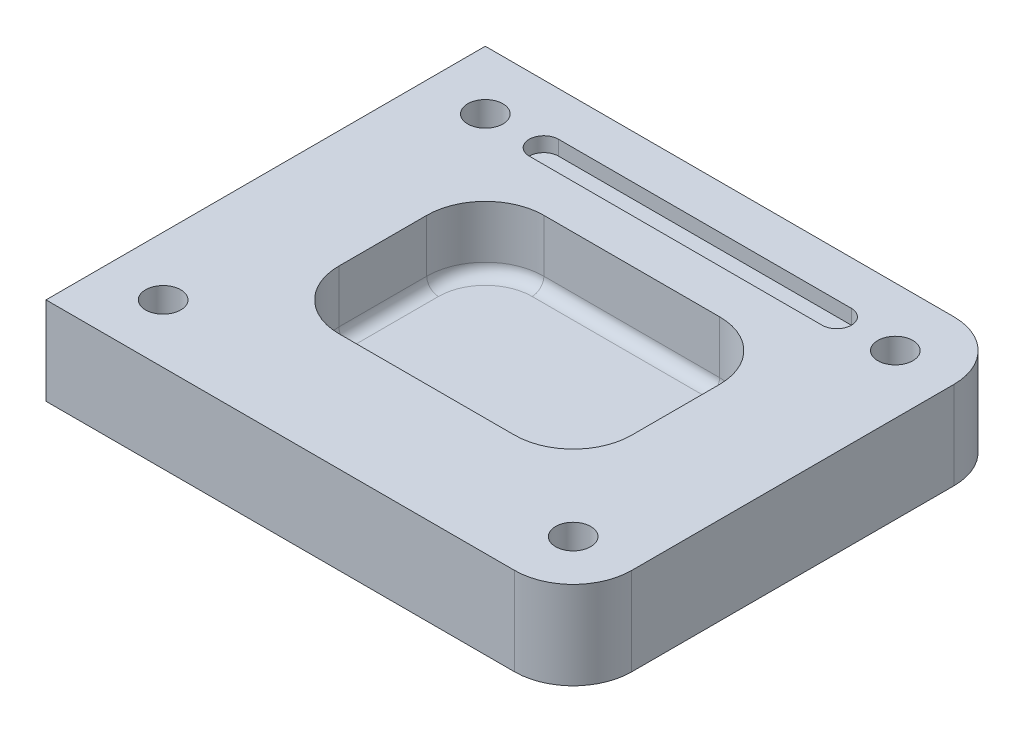
from build123d import *

# Parameters (mm, degrees)
SKETCH1_W                  = 180
SKETCH1_H                  = 150
BOSS_EXTRUDE1_DEPTH        = 30
F_16_0MM_DOWEL_HOLE1_D     = 12
F_16_0MM_DOWEL_HOLE1_DEPTH = 10
F_16_0MM_DOWEL_HOLE1_TIP   = 3.605163714
SKETCH5_W                  = 100
SKETCH5_H                  = 70
CUT_EXTRUDE1_DEPTH         = 22
FILLET1_R                  = 20
FILLET2_R                  = 20
CUT_EXTRUDE2_DEPTH         = 5
FILLET3_R                  = 4


with BuildPart() as part:
    # Sketch1 → Boss-Extrude1 (new body)
    with BuildSketch(Plane(origin=(0, 0, 0), x_dir=(1, 0, 0), z_dir=(0, 1, 0))):
        Rectangle(SKETCH1_W, SKETCH1_H)
    extrude(amount=BOSS_EXTRUDE1_DEPTH)

    # Ø16.0mm Dowel Hole1
    with Locations(Plane(origin=(-70, 30, 55), x_dir=(0, 0, 1), z_dir=(0, 1, 0))):
        with Locations((0, 0), (-110, 0), (-110, 140), (0, 140)):
            Hole(F_16_0MM_DOWEL_HOLE1_D / 2, depth=F_16_0MM_DOWEL_HOLE1_DEPTH)
            with Locations((0, 0, -(F_16_0MM_DOWEL_HOLE1_DEPTH + F_16_0MM_DOWEL_HOLE1_TIP / 2))):  # 118° drill point
                Cone(0, F_16_0MM_DOWEL_HOLE1_D / 2, F_16_0MM_DOWEL_HOLE1_TIP, mode=Mode.SUBTRACT)

    # Sketch5 → Cut-Extrude1 (cut)
    with BuildSketch(Plane(origin=(0, 30, 0), x_dir=(1, 0, 0), z_dir=(0, 1, 0))):
        Rectangle(SKETCH5_W, SKETCH5_H)
    extrude(amount=-CUT_EXTRUDE1_DEPTH, mode=Mode.SUBTRACT)

    # Fillet1
    fillet1_edges = [part.edges().sort_by_distance(p)[0] for p in [
        (50, 19, -35),
        (-50, 19, -35),
        (-50, 19, 35),
        (50, 19, 35),
    ]]
    fillet(fillet1_edges, radius=FILLET1_R)

    # Fillet2
    fillet2_edges = [part.edges().sort_by_distance(p)[0] for p in [
        (90, 15, 75),
        (90, 15, -75),
    ]]
    fillet(fillet2_edges, radius=FILLET2_R)

    # Sketch6 → Cut-Extrude2 (cut)
    with BuildSketch(Plane(origin=(0, 30, 0), x_dir=(1, 0, 0), z_dir=(0, 1, 0))):
        with BuildLine():
            Line((-50, 60), (50, 60))
            ThreePointArc((50, 60), (55, 55), (50, 50))
            Line((50, 50), (-50, 50))
            ThreePointArc((-50, 50), (-55, 55), (-50, 60))
        make_face()
    extrude(amount=-CUT_EXTRUDE2_DEPTH, mode=Mode.SUBTRACT)

    # Fillet3
    fillet3_edges = [part.edges().sort_by_distance(p)[0] for p in [
        (50, 8, 0),
        (0, 8, 35),
        (0, 8, -35),
        (-50, 8, 0),
        (-44.142135624, 8, -29.142135624),
        (44.142135624, 8, -29.142135624),
        (-44.142135624, 8, 29.142135624),
        (44.142135624, 8, 29.142135624),
    ]]
    fillet(fillet3_edges, radius=FILLET3_R)


solid = part.part
